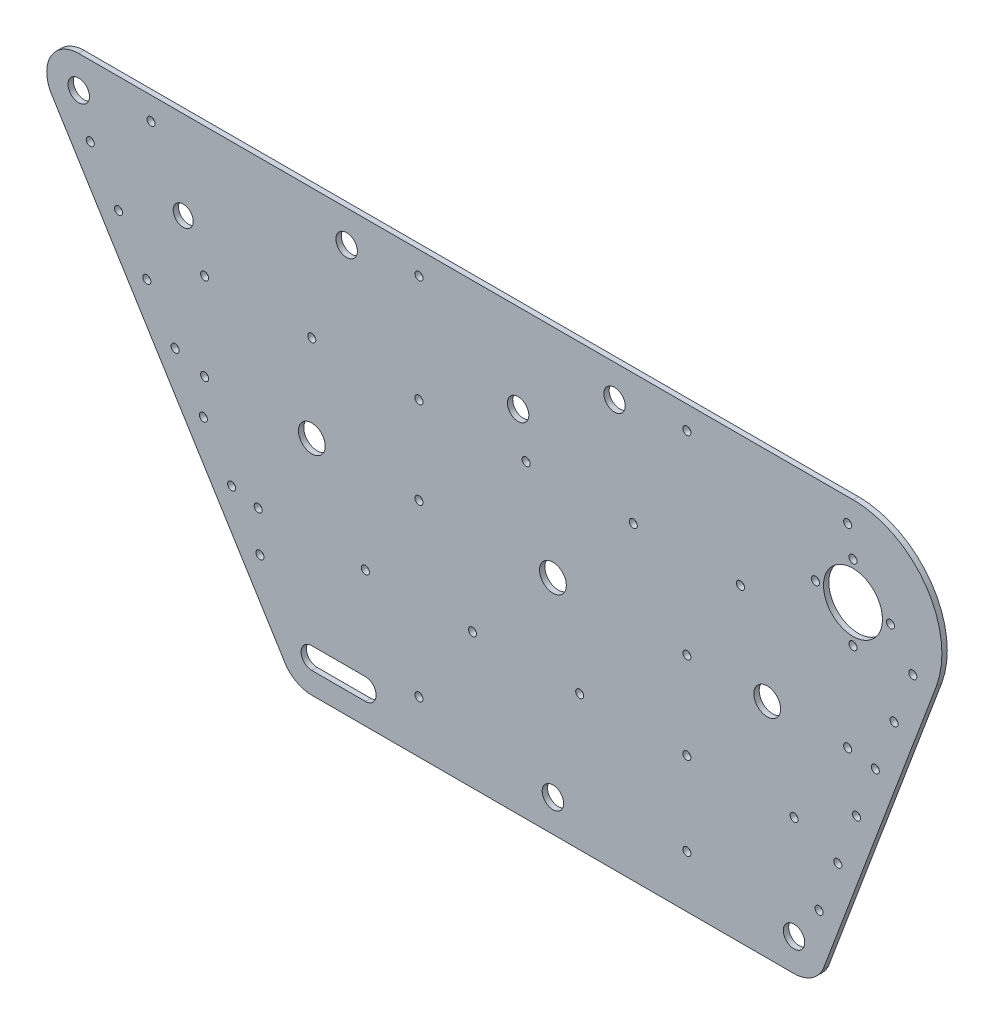
from build123d import *

# Parameters (mm, degrees)
BOSS_EXTRUDE1_DEPTH = 2


with BuildPart() as part:
    # Sketch2 → Boss-Extrude1 (new body)
    with BuildSketch(Plane.XY):
        with BuildLine():
            Line((182.961665791, 145.197671552), (-106.00519968, 144.943614194))
            add(Edge.make_bspline(
                [(-106.00519968, 144.943614194), (-127.679024036, 144.924558741), (-116.08546313, 126.611232779)],
                knots=[0.000879148, 0.000879148, 0.000879148, 2.135198153, 2.135198153, 2.135198153], degree=2, weights=[1, 0.482613975, 1]))
            Line((-116.08546313, 126.611232779), (-29.701931061, -12.425576557))
            add(Edge.make_bspline(
                [(-29.701931061, -12.425576557), (-26.369513305, -19.000000017), (-18.999049973, -19)],
                knots=[2.039949792, 2.039949792, 2.039949792, 3.141592656, 3.141592656, 3.141592656], degree=2, weights=[1, 0.852094883, 1]))
            Line((-18.999049973, -19), (160.991950179, -19))
            add(Edge.make_bspline(
                [(160.991950179, -19), (168.691832414, -18.999999885), (171.900116679, -12)],
                knots=[3.141592668, 3.141592668, 3.141592668, 4.282613549, 4.282613549, 4.282613549], degree=2, weights=[1, 0.841625416, 1]))
            Line((171.900116679, -12), (214.06903129, 100.332253713))
            add(Edge.make_bspline(
                [(214.06903129, 100.332253713), (230.926325183, 145.237792118), (182.96308424, 145.197672769)],
                knots=[4.353256006, 4.353256006, 4.353256006, 6.284014289, 6.284014289, 6.284014289], degree=2, weights=[1, 0.569095733, 0.999977608]))
            Line((182.96308424, 145.197672799), (182.961665791, 145.197671552))
        make_face()
        with BuildLine():
            add(Edge.make_bspline(
                [(-38.361920415, 18.171266638), (-40.959866722, 18.171266638), (-39.660893568, 15.921266638), (-38.361920415, 13.671266638), (-37.062947261, 15.921266638), (-35.763974107, 18.171266638), (-38.361920415, 18.171266638)],
                knots=[0, 0, 0, 2.094395102, 2.094395102, 4.188790205, 4.188790205, 6.283185307, 6.283185307, 6.283185307], degree=2, weights=[1, 0.5, 1, 0.5, 1, 0.5, 1]))
        make_face(mode=Mode.SUBTRACT)
        with BuildLine():
            add(Edge.make_bspline(
                [(-18.99905, -3), (-22.99885, -3), (-22.99885, -7), (-22.99885, -11), (-18.99905, -11)],
                knots=[3.141592654, 3.141592654, 3.141592654, 4.71238898, 4.71238898, 6.283185307, 6.283185307, 6.283185307], degree=2, weights=[1, 0.707106781, 1, 0.707106781, 1]))
            Line((-18.99905, -3), (0.99995, -3))
            add(Edge.make_bspline(
                [(0.99995, -11), (4.99975, -11), (4.99975, -7), (4.99975, -3), (0.99995, -3)],
                knots=[3.141592654, 3.141592654, 3.141592654, 4.71238898, 4.71238898, 6.283185307, 6.283185307, 6.283185307], degree=2, weights=[1, 0.707106781, 1, 0.707106781, 1]))
            Line((0.99995, -11), (-18.99905, -11))
        make_face(mode=Mode.SUBTRACT)
        with BuildLine():
            add(Edge.make_bspline(
                [(20.99895, 2), (18.401003692, 2), (19.699976846, -0.25), (20.99895, -2.5), (22.297923154, -0.25), (23.596896308, 2), (20.99895, 2)],
                knots=[0, 0, 0, 2.094395102, 2.094395102, 4.188790205, 4.188790205, 6.283185307, 6.283185307, 6.283185307], degree=2, weights=[1, 0.5, 1, 0.5, 1, 0.5, 1]))
        make_face(mode=Mode.SUBTRACT)
        with BuildLine():
            add(Edge.make_bspline(
                [(-38.99805, 32.999994311), (-41.595996308, 32.999994311), (-40.297023154, 30.749994311), (-38.99805, 28.499994311), (-37.699076846, 30.749994311), (-36.400103692, 32.999994311), (-38.99805, 32.999994311)],
                knots=[0, 0, 0, 2.094395102, 2.094395102, 4.188790205, 4.188790205, 6.283185307, 6.283185307, 6.283185307], degree=2, weights=[1, 0.5, 1, 0.5, 1, 0.5, 1]))
        make_face(mode=Mode.SUBTRACT)
        with BuildLine():
            add(Edge.make_bspline(
                [(-48.916261932, 35.158786529), (-51.51420824, 35.158786529), (-50.215235086, 32.908786529), (-48.916261932, 30.658786529), (-47.617288778, 32.908786529), (-46.318315625, 35.158786529), (-48.916261932, 35.158786529)],
                knots=[0, 0, 0, 2.094395102, 2.094395102, 4.188790205, 4.188790205, 6.283185307, 6.283185307, 6.283185307], degree=2, weights=[1, 0.5, 1, 0.5, 1, 0.5, 1]))
        make_face(mode=Mode.SUBTRACT)
        with BuildLine():
            add(Edge.make_bspline(
                [(-59.470762984, 52.146563195), (-62.068709292, 52.146563195), (-60.769736138, 49.896563195), (-59.470762984, 47.646563195), (-58.171789831, 49.896563195), (-56.872816677, 52.146563195), (-59.470762984, 52.146563195)],
                knots=[0, 0, 0, 2.094395102, 2.094395102, 4.188790205, 4.188790205, 6.283185307, 6.283185307, 6.283185307], degree=2, weights=[1, 0.5, 1, 0.5, 1, 0.5, 1]))
        make_face(mode=Mode.SUBTRACT)
        with BuildLine():
            add(Edge.make_bspline(
                [(0.99995, 32.999992415), (-1.597996308, 32.999992415), (-0.299023154, 30.749992415), (0.99995, 28.499992415), (2.298923154, 30.749992415), (3.597896308, 32.999992415), (0.99995, 32.999992415)],
                knots=[0, 0, 0, 2.094395102, 2.094395102, 4.188790205, 4.188790205, 6.283185307, 6.283185307, 6.283185307], degree=2, weights=[1, 0.5, 1, 0.5, 1, 0.5, 1]))
        make_face(mode=Mode.SUBTRACT)
        with BuildLine():
            add(Edge.make_bspline(
                [(40.99795, 32.999988622), (38.400003692, 32.999988622), (39.698976846, 30.749988622), (40.99795, 28.499988622), (42.296923154, 30.749988622), (43.595896308, 32.999988622), (40.99795, 32.999988622)],
                knots=[0, 0, 0, 2.094395102, 2.094395102, 4.188790205, 4.188790205, 6.283185307, 6.283185307, 6.283185307], degree=2, weights=[1, 0.5, 1, 0.5, 1, 0.5, 1]))
        make_face(mode=Mode.SUBTRACT)
        with BuildLine():
            add(Edge.make_bspline(
                [(70.99645, -3), (64.06859318, -3), (67.53252159, -9), (70.99645, -15), (74.46037841, -9), (77.92430682, -3), (70.99645, -3)],
                knots=[0, 0, 0, 2.094395102, 2.094395102, 4.188790205, 4.188790205, 6.283185307, 6.283185307, 6.283185307], degree=2, weights=[1, 0.5, 1, 0.5, 1, 0.5, 1]))
        make_face(mode=Mode.SUBTRACT)
        with BuildLine():
            add(Edge.make_bspline(
                [(120.99395, 2), (118.396003692, 2), (119.694976846, -0.25), (120.99395, -2.5), (122.292923154, -0.25), (123.591896308, 2), (120.99395, 2)],
                knots=[0, 0, 0, 2.094395102, 2.094395102, 4.188790205, 4.188790205, 6.283185307, 6.283185307, 6.283185307], degree=2, weights=[1, 0.5, 1, 0.5, 1, 0.5, 1]))
        make_face(mode=Mode.SUBTRACT)
        with BuildLine():
            add(Edge.make_bspline(
                [(160.99195, -3), (154.06409318, -3), (157.52802159, -9), (160.99195, -15), (164.45587841, -9), (167.91980682, -3), (160.99195, -3)],
                knots=[0, 0, 0, 2.094395102, 2.094395102, 4.188790205, 4.188790205, 6.283185307, 6.283185307, 6.283185307], degree=2, weights=[1, 0.5, 1, 0.5, 1, 0.5, 1]))
        make_face(mode=Mode.SUBTRACT)
        with BuildLine():
            add(Edge.make_bspline(
                [(170.332531489, 7.618627774), (167.734585182, 7.618627774), (169.033558335, 5.368627774), (170.332531489, 3.118627774), (171.631504643, 5.368627774), (172.930477797, 7.618627774), (170.332531489, 7.618627774)],
                knots=[0, 0, 0, 2.094395102, 2.094395102, 4.188790205, 4.188790205, 6.283185307, 6.283185307, 6.283185307], degree=2, weights=[1, 0.5, 1, 0.5, 1, 0.5, 1]))
        make_face(mode=Mode.SUBTRACT)
        with BuildLine():
            add(Edge.make_bspline(
                [(80.99595, 32.999985778), (78.398003692, 32.999985778), (79.696976846, 30.749985778), (80.99595, 28.499985778), (82.294923154, 30.749985778), (83.593896308, 32.999985778), (80.99595, 32.999985778)],
                knots=[0, 0, 0, 2.094395102, 2.094395102, 4.188790205, 4.188790205, 6.283185307, 6.283185307, 6.283185307], degree=2, weights=[1, 0.5, 1, 0.5, 1, 0.5, 1]))
        make_face(mode=Mode.SUBTRACT)
        with BuildLine():
            add(Edge.make_bspline(
                [(120.99395, 32.999981037), (118.396003692, 32.999981037), (119.694976846, 30.749981037), (120.99395, 28.499981037), (122.292923154, 30.749981037), (123.591896308, 32.999981037), (120.99395, 32.999981037)],
                knots=[0, 0, 0, 2.094395102, 2.094395102, 4.188790205, 4.188790205, 6.283185307, 6.283185307, 6.283185307], degree=2, weights=[1, 0.5, 1, 0.5, 1, 0.5, 1]))
        make_face(mode=Mode.SUBTRACT)
        with BuildLine():
            add(Edge.make_bspline(
                [(160.99195, 32.999978192), (158.394003692, 32.999978192), (159.692976846, 30.749978192), (160.99195, 28.499978192), (162.290923154, 30.749978192), (163.589896308, 32.999978192), (160.99195, 32.999978192)],
                knots=[0, 0, 0, 2.094395102, 2.094395102, 4.188790205, 4.188790205, 6.283185307, 6.283185307, 6.283185307], degree=2, weights=[1, 0.5, 1, 0.5, 1, 0.5, 1]))
        make_face(mode=Mode.SUBTRACT)
        with BuildLine():
            add(Edge.make_bspline(
                [(177.330672341, 26.354456596), (174.732726034, 26.354456596), (176.031699187, 24.104456596), (177.330672341, 21.854456596), (178.629645495, 24.104456596), (179.928618649, 26.354456596), (177.330672341, 26.354456596)],
                knots=[0, 0, 0, 2.094395102, 2.094395102, 4.188790205, 4.188790205, 6.283185307, 6.283185307, 6.283185307], degree=2, weights=[1, 0.5, 1, 0.5, 1, 0.5, 1]))
        make_face(mode=Mode.SUBTRACT)
        with BuildLine():
            add(Edge.make_bspline(
                [(184.328557385, 45.089600555), (181.730611078, 45.089600555), (183.029584232, 42.839600555), (184.328557385, 40.589600555), (185.627530539, 42.839600555), (186.926503693, 45.089600555), (184.328557385, 45.089600555)],
                knots=[0, 0, 0, 2.094395102, 2.094395102, 4.188790205, 4.188790205, 6.283185307, 6.283185307, 6.283185307], degree=2, weights=[1, 0.5, 1, 0.5, 1, 0.5, 1]))
        make_face(mode=Mode.SUBTRACT)
        with BuildLine():
            add(Edge.make_bspline(
                [(191.32646769, 63.824812144), (188.728521383, 63.824812144), (190.027494537, 61.574812144), (191.32646769, 59.324812144), (192.625440844, 61.574812144), (193.924413998, 63.824812144), (191.32646769, 63.824812144)],
                knots=[0, 0, 0, 2.094395102, 2.094395102, 4.188790205, 4.188790205, 6.283185307, 6.283185307, 6.283185307], degree=2, weights=[1, 0.5, 1, 0.5, 1, 0.5, 1]))
        make_face(mode=Mode.SUBTRACT)
        with BuildLine():
            add(Edge.make_bspline(
                [(-70.02547384, 69.134677545), (-72.623420147, 69.134677545), (-71.324446993, 66.884677545), (-70.02547384, 64.634677545), (-68.726500686, 66.884677545), (-67.427527532, 69.134677545), (-70.02547384, 69.134677545)],
                knots=[0, 0, 0, 2.094395102, 2.094395102, 4.188790205, 4.188790205, 6.283185307, 6.283185307, 6.283185307], degree=2, weights=[1, 0.5, 1, 0.5, 1, 0.5, 1]))
        make_face(mode=Mode.SUBTRACT)
        with BuildLine():
            add(Edge.make_bspline(
                [(-58.99705, 65.5), (-61.594996308, 65.5), (-60.296023154, 63.25), (-58.99705, 61), (-57.698076846, 63.25), (-56.399103692, 65.5), (-58.99705, 65.5)],
                knots=[0, 0, 0, 2.094395102, 2.094395102, 4.188790205, 4.188790205, 6.283185307, 6.283185307, 6.283185307], degree=2, weights=[1, 0.5, 1, 0.5, 1, 0.5, 1]))
        make_face(mode=Mode.SUBTRACT)
        with BuildLine():
            add(Edge.make_bspline(
                [(-91.134705429, 103.110600241), (-93.732651737, 103.110600241), (-92.433678583, 100.860600241), (-91.134705429, 98.610600241), (-89.835732276, 100.860600241), (-88.536759122, 103.110600241), (-91.134705429, 103.110600241)],
                knots=[0, 0, 0, 2.094395102, 2.094395102, 4.188790205, 4.188790205, 6.283185307, 6.283185307, 6.283185307], degree=2, weights=[1, 0.5, 1, 0.5, 1, 0.5, 1]))
        make_face(mode=Mode.SUBTRACT)
        with BuildLine():
            add(Edge.make_bspline(
                [(-80.580283096, 86.122950275), (-83.178229403, 86.122950275), (-81.87925625, 83.872950275), (-80.580283096, 81.622950275), (-79.281309942, 83.872950275), (-77.982336788, 86.122950275), (-80.580283096, 86.122950275)],
                knots=[0, 0, 0, 2.094395102, 2.094395102, 4.188790205, 4.188790205, 6.283185307, 6.283185307, 6.283185307], degree=2, weights=[1, 0.5, 1, 0.5, 1, 0.5, 1]))
        make_face(mode=Mode.SUBTRACT)
        with BuildLine():
            add(Edge.make_bspline(
                [(-58.99705, 98), (-61.594996308, 98), (-60.296023154, 95.75), (-58.99705, 93.5), (-57.698076846, 95.75), (-56.399103692, 98), (-58.99705, 98)],
                knots=[0, 0, 0, 2.094395102, 2.094395102, 4.188790205, 4.188790205, 6.283185307, 6.283185307, 6.283185307], degree=2, weights=[1, 0.5, 1, 0.5, 1, 0.5, 1]))
        make_face(mode=Mode.SUBTRACT)
        with BuildLine():
            add(Edge.make_bspline(
                [(-18.99905, 69), (-27.658871025, 69), (-23.328960513, 61.5), (-18.99905, 54), (-14.669139487, 61.5), (-10.339228975, 69), (-18.99905, 69)],
                knots=[0, 0, 0, 2.094395102, 2.094395102, 4.188790205, 4.188790205, 6.283185307, 6.283185307, 6.283185307], degree=2, weights=[1, 0.5, 1, 0.5, 1, 0.5, 1]))
        make_face(mode=Mode.SUBTRACT)
        with BuildLine():
            add(Edge.make_bspline(
                [(20.99895, 65.5), (18.401003692, 65.5), (19.699976846, 63.25), (20.99895, 61), (22.297923154, 63.25), (23.596896308, 65.5), (20.99895, 65.5)],
                knots=[0, 0, 0, 2.094395102, 2.094395102, 4.188790205, 4.188790205, 6.283185307, 6.283185307, 6.283185307], degree=2, weights=[1, 0.5, 1, 0.5, 1, 0.5, 1]))
        make_face(mode=Mode.SUBTRACT)
        with BuildLine():
            add(Edge.make_bspline(
                [(-18.99905, 98), (-21.596996308, 98), (-20.298023154, 95.75), (-18.99905, 93.5), (-17.700076846, 95.75), (-16.401103692, 98), (-18.99905, 98)],
                knots=[0, 0, 0, 2.094395102, 2.094395102, 4.188790205, 4.188790205, 6.283185307, 6.283185307, 6.283185307], degree=2, weights=[1, 0.5, 1, 0.5, 1, 0.5, 1]))
        make_face(mode=Mode.SUBTRACT)
        with BuildLine():
            add(Edge.make_bspline(
                [(20.99895, 98), (18.401003692, 98), (19.699976846, 95.75), (20.99895, 93.5), (22.297923154, 95.75), (23.596896308, 98), (20.99895, 98)],
                knots=[0, 0, 0, 2.094395102, 2.094395102, 4.188790205, 4.188790205, 6.283185307, 6.283185307, 6.283185307], degree=2, weights=[1, 0.5, 1, 0.5, 1, 0.5, 1]))
        make_face(mode=Mode.SUBTRACT)
        with BuildLine():
            add(Edge.make_bspline(
                [(-101.689209002, 120.098380963), (-104.287155309, 120.098380963), (-102.988182156, 117.848380963), (-101.689209002, 115.598380963), (-100.390235848, 117.848380963), (-99.091262694, 120.098380963), (-101.689209002, 120.098380963)],
                knots=[0, 0, 0, 2.094395102, 2.094395102, 4.188790205, 4.188790205, 6.283185307, 6.283185307, 6.283185307], degree=2, weights=[1, 0.5, 1, 0.5, 1, 0.5, 1]))
        make_face(mode=Mode.SUBTRACT)
        with BuildLine():
            add(Edge.make_bspline(
                [(-66.99665, 115.75), (-73.491515769, 115.75), (-70.244082884, 110.125), (-66.99665, 104.5), (-63.749217116, 110.125), (-60.501784231, 115.75), (-66.99665, 115.75)],
                knots=[0, 0, 0, 2.094395102, 2.094395102, 4.188790205, 4.188790205, 6.283185307, 6.283185307, 6.283185307], degree=2, weights=[1, 0.5, 1, 0.5, 1, 0.5, 1]))
        make_face(mode=Mode.SUBTRACT)
        with BuildLine():
            add(Edge.make_bspline(
                [(-105.9947, 137), (-112.92255682, 137), (-109.45862841, 131), (-105.9947, 125), (-102.53077159, 131), (-99.06684318, 137), (-105.9947, 137)],
                knots=[0, 0, 0, 2.094395102, 2.094395102, 4.188790205, 4.188790205, 6.283185307, 6.283185307, 6.283185307], degree=2, weights=[1, 0.5, 1, 0.5, 1, 0.5, 1]))
        make_face(mode=Mode.SUBTRACT)
        with BuildLine():
            add(Edge.make_bspline(
                [(-78.996040132, 138), (-81.59398644, 138), (-80.295013286, 135.75), (-78.996040132, 133.5), (-77.697066978, 135.75), (-76.398093824, 138), (-78.996040132, 138)],
                knots=[0, 0, 0, 2.094395102, 2.094395102, 4.188790205, 4.188790205, 6.283185307, 6.283185307, 6.283185307], degree=2, weights=[1, 0.5, 1, 0.5, 1, 0.5, 1]))
        make_face(mode=Mode.SUBTRACT)
        with BuildLine():
            add(Edge.make_bspline(
                [(-5.9997, 137), (-12.92755682, 137), (-9.46362841, 131), (-5.9997, 125), (-2.53577159, 131), (0.92815682, 137), (-5.9997, 137)],
                knots=[0, 0, 0, 2.094395102, 2.094395102, 4.188790205, 4.188790205, 6.283185307, 6.283185307, 6.283185307], degree=2, weights=[1, 0.5, 1, 0.5, 1, 0.5, 1]))
        make_face(mode=Mode.SUBTRACT)
        with BuildLine():
            add(Edge.make_bspline(
                [(20.99895, 138), (18.401003692, 138), (19.699976846, 135.75), (20.99895, 133.5), (22.297923154, 135.75), (23.596896308, 138), (20.99895, 138)],
                knots=[0, 0, 0, 2.094395102, 2.094395102, 4.188790205, 4.188790205, 6.283185307, 6.283185307, 6.283185307], degree=2, weights=[1, 0.5, 1, 0.5, 1, 0.5, 1]))
        make_face(mode=Mode.SUBTRACT)
        with BuildLine():
            add(Edge.make_bspline(
                [(70.99645, 69), (62.336628975, 69), (66.666539487, 61.5), (70.99645, 54), (75.326360513, 61.5), (79.656271025, 69), (70.99645, 69)],
                knots=[0, 0, 0, 2.094395102, 2.094395102, 4.188790205, 4.188790205, 6.283185307, 6.283185307, 6.283185307], degree=2, weights=[1, 0.5, 1, 0.5, 1, 0.5, 1]))
        make_face(mode=Mode.SUBTRACT)
        with BuildLine():
            add(Edge.make_bspline(
                [(120.99395, 65.5), (118.396003692, 65.5), (119.694976846, 63.25), (120.99395, 61), (122.292923154, 63.25), (123.591896308, 65.5), (120.99395, 65.5)],
                knots=[0, 0, 0, 2.094395102, 2.094395102, 4.188790205, 4.188790205, 6.283185307, 6.283185307, 6.283185307], degree=2, weights=[1, 0.5, 1, 0.5, 1, 0.5, 1]))
        make_face(mode=Mode.SUBTRACT)
        with BuildLine():
            add(Edge.make_bspline(
                [(60.99695, 98), (58.399003692, 98), (59.697976846, 95.75), (60.99695, 93.5), (62.295923154, 95.75), (63.594896308, 98), (60.99695, 98)],
                knots=[0, 0, 0, 2.094395102, 2.094395102, 4.188790205, 4.188790205, 6.283185307, 6.283185307, 6.283185307], degree=2, weights=[1, 0.5, 1, 0.5, 1, 0.5, 1]))
        make_face(mode=Mode.SUBTRACT)
        with BuildLine():
            add(Edge.make_bspline(
                [(100.99495, 98), (98.397003692, 98), (99.695976846, 95.75), (100.99495, 93.5), (102.293923154, 95.75), (103.592896308, 98), (100.99495, 98)],
                knots=[0, 0, 0, 2.094395102, 2.094395102, 4.188790205, 4.188790205, 6.283185307, 6.283185307, 6.283185307], degree=2, weights=[1, 0.5, 1, 0.5, 1, 0.5, 1]))
        make_face(mode=Mode.SUBTRACT)
        with BuildLine():
            add(Edge.make_bspline(
                [(140.99295, 98), (138.395003692, 98), (139.693976846, 95.75), (140.99295, 93.5), (142.291923154, 95.75), (143.590896308, 98), (140.99295, 98)],
                knots=[0, 0, 0, 2.094395102, 2.094395102, 4.188790205, 4.188790205, 6.283185307, 6.283185307, 6.283185307], degree=2, weights=[1, 0.5, 1, 0.5, 1, 0.5, 1]))
        make_face(mode=Mode.SUBTRACT)
        with BuildLine():
            add(Edge.make_bspline(
                [(150.99245, 69), (142.332628975, 69), (146.662539487, 61.5), (150.99245, 54), (155.322360513, 61.5), (159.652271025, 69), (150.99245, 69)],
                knots=[0, 0, 0, 2.094395102, 2.094395102, 4.188790205, 4.188790205, 6.283185307, 6.283185307, 6.283185307], degree=2, weights=[1, 0.5, 1, 0.5, 1, 0.5, 1]))
        make_face(mode=Mode.SUBTRACT)
        with BuildLine():
            add(Edge.make_bspline(
                [(180.99095, 65.5), (178.393003692, 65.5), (179.691976846, 63.25), (180.99095, 61), (182.289923154, 63.25), (183.588896308, 65.5), (180.99095, 65.5)],
                knots=[0, 0, 0, 2.094395102, 2.094395102, 4.188790205, 4.188790205, 6.283185307, 6.283185307, 6.283185307], degree=2, weights=[1, 0.5, 1, 0.5, 1, 0.5, 1]))
        make_face(mode=Mode.SUBTRACT)
        with BuildLine():
            add(Edge.make_bspline(
                [(198.324441471, 82.560193672), (195.726495163, 82.560193672), (197.025468317, 80.310193672), (198.324441471, 78.060193672), (199.623414624, 80.310193672), (200.922387778, 82.560193672), (198.324441471, 82.560193672)],
                knots=[0, 0, 0, 2.094395102, 2.094395102, 4.188790205, 4.188790205, 6.283185307, 6.283185307, 6.283185307], degree=2, weights=[1, 0.5, 1, 0.5, 1, 0.5, 1]))
        make_face(mode=Mode.SUBTRACT)
        with BuildLine():
            add(Edge.make_bspline(
                [(182.99085, 99.5), (180.392903692, 99.5), (181.691876846, 97.25), (182.99085, 95), (184.289823154, 97.25), (185.588796308, 99.5), (182.99085, 99.5)],
                knots=[0, 0, 0, 2.094395102, 2.094395102, 4.188790205, 4.188790205, 6.283185307, 6.283185307, 6.283185307], degree=2, weights=[1, 0.5, 1, 0.5, 1, 0.5, 1]))
        make_face(mode=Mode.SUBTRACT)
        with BuildLine():
            add(Edge.make_bspline(
                [(205.322481122, 101.295751553), (202.724534814, 101.295751553), (204.023507968, 99.045751553), (205.322481122, 96.795751553), (206.621454275, 99.045751553), (207.920427429, 101.295751553), (205.322481122, 101.295751553)],
                knots=[0, 0, 0, 2.094395102, 2.094395102, 4.188790205, 4.188790205, 6.283185307, 6.283185307, 6.283185307], degree=2, weights=[1, 0.5, 1, 0.5, 1, 0.5, 1]))
        make_face(mode=Mode.SUBTRACT)
        with BuildLine():
            add(Edge.make_bspline(
                [(57.9971, 116), (51.06924318, 116), (54.53317159, 110), (57.9971, 104), (61.46102841, 110), (64.92495682, 116), (57.9971, 116)],
                knots=[0, 0, 0, 2.094395102, 2.094395102, 4.188790205, 4.188790205, 6.283185307, 6.283185307, 6.283185307], degree=2, weights=[1, 0.5, 1, 0.5, 1, 0.5, 1]))
        make_face(mode=Mode.SUBTRACT)
        with BuildLine():
            add(Edge.make_bspline(
                [(93.995220809, 137), (87.067363989, 137), (90.531292399, 131), (93.995220809, 125), (97.459149219, 131), (100.923077629, 137), (93.995220809, 137)],
                knots=[0, 0, 0, 2.094395102, 2.094395102, 4.188790205, 4.188790205, 6.283185307, 6.283185307, 6.283185307], degree=2, weights=[1, 0.5, 1, 0.5, 1, 0.5, 1]))
        make_face(mode=Mode.SUBTRACT)
        with BuildLine():
            add(Edge.make_bspline(
                [(120.99395, 138), (118.396003692, 138), (119.694976846, 135.75), (120.99395, 133.5), (122.292923154, 135.75), (123.591896308, 138), (120.99395, 138)],
                knots=[0, 0, 0, 2.094395102, 2.094395102, 4.188790205, 4.188790205, 6.283185307, 6.283185307, 6.283185307], degree=2, weights=[1, 0.5, 1, 0.5, 1, 0.5, 1]))
        make_face(mode=Mode.SUBTRACT)
        with BuildLine():
            add(Edge.make_bspline(
                [(168.99155, 113.5), (166.393603692, 113.5), (167.692576846, 111.25), (168.99155, 109), (170.290523154, 111.25), (171.589496308, 113.5), (168.99155, 113.5)],
                knots=[0, 0, 0, 2.094395102, 2.094395102, 4.188790205, 4.188790205, 6.283185307, 6.283185307, 6.283185307], degree=2, weights=[1, 0.5, 1, 0.5, 1, 0.5, 1]))
        make_face(mode=Mode.SUBTRACT)
        with BuildLine():
            add(Edge.make_bspline(
                [(182.99085, 123), (163.939243745, 123), (173.465046872, 106.5), (182.99085, 90), (192.516653128, 106.5), (202.042456255, 123), (182.99085, 123)],
                knots=[0, 0, 0, 2.094395102, 2.094395102, 4.188790205, 4.188790205, 6.283185307, 6.283185307, 6.283185307], degree=2, weights=[1, 0.5, 1, 0.5, 1, 0.5, 1]))
        make_face(mode=Mode.SUBTRACT)
        with BuildLine():
            add(Edge.make_bspline(
                [(196.99015, 113.5), (194.392203692, 113.5), (195.691176846, 111.25), (196.99015, 109), (198.289123154, 111.25), (199.588096308, 113.5), (196.99015, 113.5)],
                knots=[0, 0, 0, 2.094395102, 2.094395102, 4.188790205, 4.188790205, 6.283185307, 6.283185307, 6.283185307], degree=2, weights=[1, 0.5, 1, 0.5, 1, 0.5, 1]))
        make_face(mode=Mode.SUBTRACT)
        with BuildLine():
            add(Edge.make_bspline(
                [(182.99085, 127.5), (180.392903692, 127.5), (181.691876846, 125.25), (182.99085, 123), (184.289823154, 125.25), (185.588796308, 127.5), (182.99085, 127.5)],
                knots=[0, 0, 0, 2.094395102, 2.094395102, 4.188790205, 4.188790205, 6.283185307, 6.283185307, 6.283185307], degree=2, weights=[1, 0.5, 1, 0.5, 1, 0.5, 1]))
        make_face(mode=Mode.SUBTRACT)
        with BuildLine():
            add(Edge.make_bspline(
                [(180.99095, 138), (178.393003692, 138), (179.691976846, 135.75), (180.99095, 133.5), (182.289923154, 135.75), (183.588896308, 138), (180.99095, 138)],
                knots=[0, 0, 0, 2.094395102, 2.094395102, 4.188790205, 4.188790205, 6.283185307, 6.283185307, 6.283185307], degree=2, weights=[1, 0.5, 1, 0.5, 1, 0.5, 1]))
        make_face(mode=Mode.SUBTRACT)
    extrude(amount=BOSS_EXTRUDE1_DEPTH)


solid = part.part
